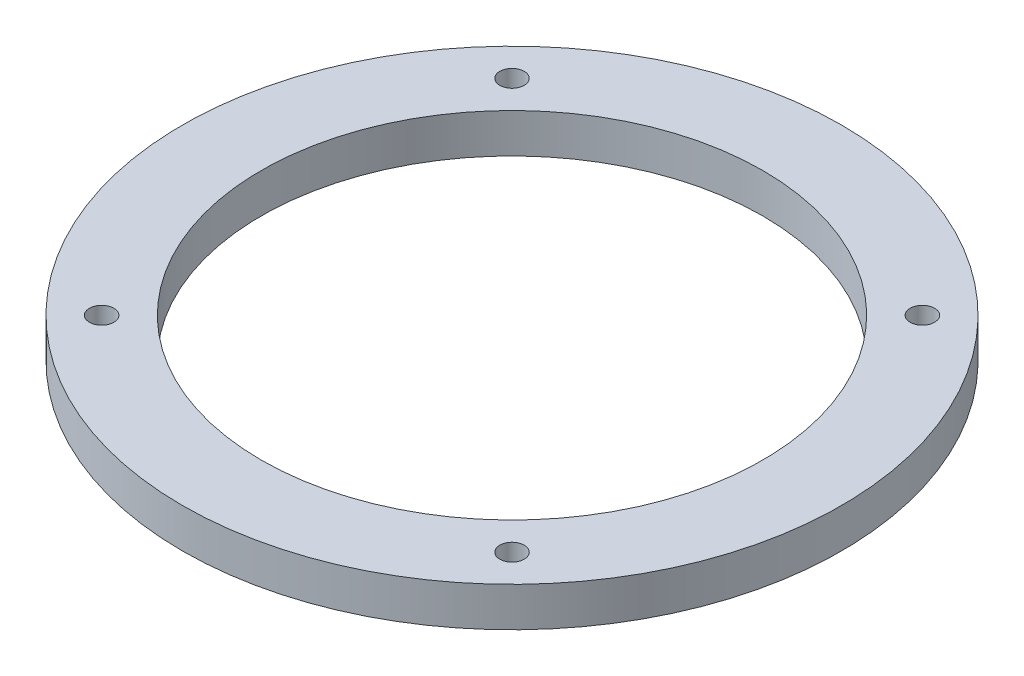
from build123d import *

# Parameters (mm, degrees)
CROQUIS1_R              = 41.8402633
CROQUIS1_R_2            = 1.55
CROQUIS1_R_3            = 31.8402633
SALIENTE_EXTRUIR1_DEPTH = 5


with BuildPart() as part:
    # Croquis1 → Saliente-Extruir1 (new body)
    with BuildSketch(Plane(origin=(0, 0, 0), x_dir=(1, 0, 0), z_dir=(0, 1, 0))):
        Circle(CROQUIS1_R)
        with Locations((-26.05, 26.05)):
            Circle(CROQUIS1_R_2, mode=Mode.SUBTRACT)
        Circle(CROQUIS1_R_3, mode=Mode.SUBTRACT)
        with Locations((26.05, 26.05)):
            Circle(CROQUIS1_R_2, mode=Mode.SUBTRACT)
        with Locations((26.05, -26.05)):
            Circle(CROQUIS1_R_2, mode=Mode.SUBTRACT)
        with Locations((-26.05, -26.05)):
            Circle(CROQUIS1_R_2, mode=Mode.SUBTRACT)
    extrude(amount=SALIENTE_EXTRUIR1_DEPTH)


solid = part.part
